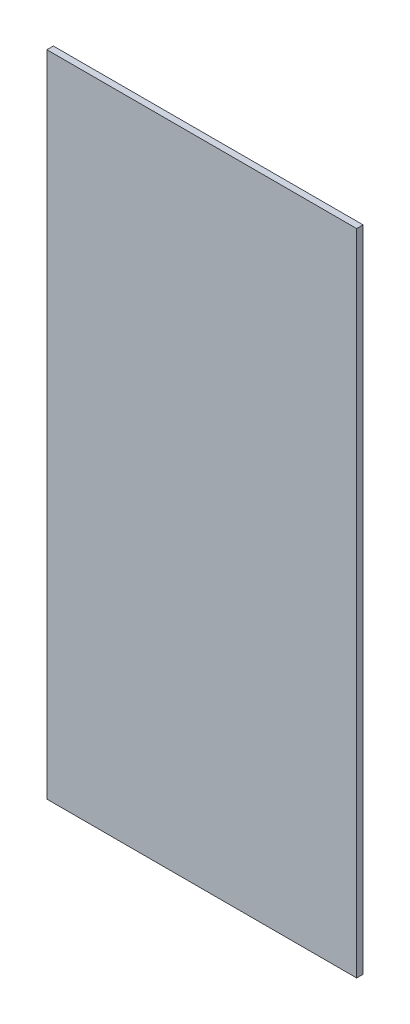
from build123d import *

# Parameters (mm, degrees)
SKETCH2_W           = 152.4
SKETCH2_H           = 319.278
BOSS_EXTRUDE1_DEPTH = 3.175


with BuildPart() as part:
    # Sketch2 → Boss-Extrude1 (new body)
    with BuildSketch(Plane.XY):
        with Locations((76.2, 159.639)):
            Rectangle(SKETCH2_W, SKETCH2_H)
    extrude(amount=BOSS_EXTRUDE1_DEPTH)


solid = part.part
